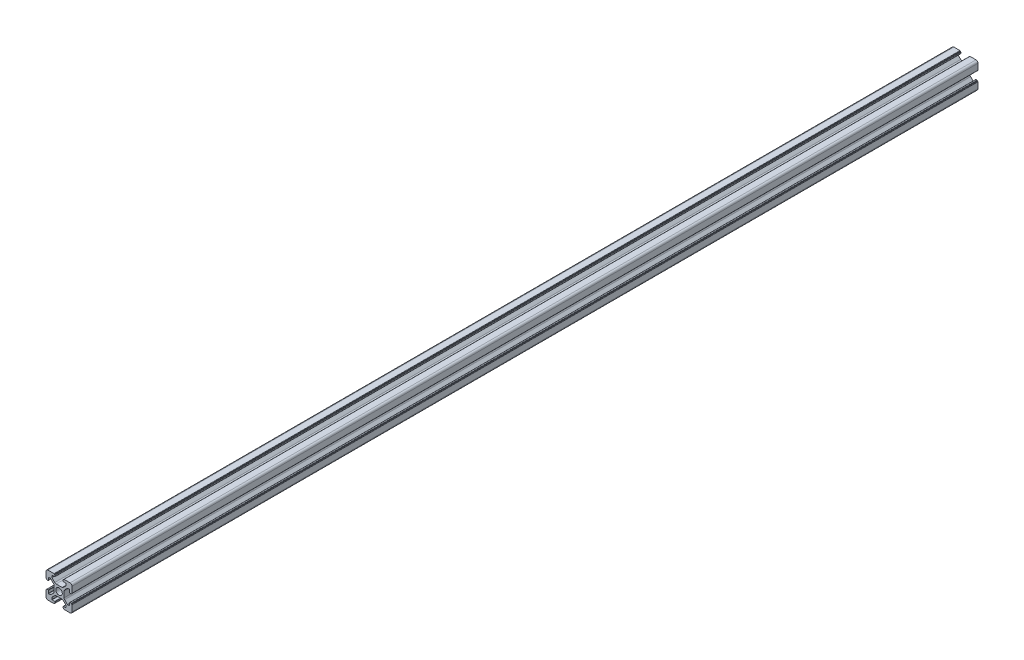
from build123d import *

# Parameters (mm, degrees)
SKETCH_1_R         = 2.5
EXTRUDE_1_DEPTH    = 1220
SKETCH1_R          = 16.771487081
CUT_EXTRUDE1_DEPTH = 525


with BuildPart() as part:
    # 草图1 → 凸台-拉伸1 (new body)
    with BuildSketch(Plane.XY):
        with BuildLine():
            Line((-8.502261885, -10.002261885), (-3.85, -10.002261885))
            ThreePointArc((-3.85, -10.002261885), (-3.673223305, -9.929038581), (-3.6, -9.752261885))
            Line((-3.6, -9.752261885), (-3.6, -9.502261885))
            Line((-3.6, -9.502261885), (-3.35, -9.502261885))
            ThreePointArc((-3.35, -9.502261885), (-3.173223305, -9.429038581), (-3.1, -9.252261885))
            Line((-3.1, -9.252261885), (-3.1, -8.45))
            ThreePointArc((-3.1, -8.45), (-3.173223305, -8.273223305), (-3.35, -8.2))
            Line((-3.35, -8.2), (-5.25, -8.2))
            ThreePointArc((-5.25, -8.2), (-5.426776695, -8.126776695), (-5.5, -7.95))
            Line((-5.5, -7.95), (-5.5, -6.664213562))
            ThreePointArc((-5.5, -6.664213562), (-5.480969883, -6.568542704), (-5.426776695, -6.487436867))
            Line((-5.426776695, -6.487436867), (-3.278679656, -4.339339828))
            ThreePointArc((-3.278679656, -4.339339828), (-2.792044633, -4.014180701), (-2.218019485, -3.9))
            Line((-2.218019485, -3.9), (2.218019485, -3.9))
            ThreePointArc((2.218019485, -3.9), (2.792044633, -4.014180701), (3.278679656, -4.339339828))
            Line((3.278679656, -4.339339828), (5.426776695, -6.487436867))
            ThreePointArc((5.426776695, -6.487436867), (5.480969883, -6.568542704), (5.5, -6.664213562))
            Line((5.5, -6.664213562), (5.5, -7.95))
            ThreePointArc((5.5, -7.95), (5.426776695, -8.126776695), (5.25, -8.2))
            Line((5.25, -8.2), (3.35, -8.2))
            ThreePointArc((3.35, -8.2), (3.173223305, -8.273223305), (3.1, -8.45))
            Line((3.1, -8.45), (3.1, -9.252261885))
            ThreePointArc((3.1, -9.252261885), (3.173223305, -9.429038581), (3.35, -9.502261885))
            Line((3.35, -9.502261885), (3.6, -9.502261885))
            Line((3.6, -9.502261885), (3.6, -9.752261885))
            ThreePointArc((3.6, -9.752261885), (3.673223305, -9.929038581), (3.85, -10.002261885))
            Line((3.85, -10.002261885), (8.502261885, -10.002261885))
            ThreePointArc((8.502261885, -10.002261885), (9.562922057, -9.562922057), (10.002261885, -8.502261885))
            Line((10.002261885, -8.502261885), (10.002261885, -3.85))
            ThreePointArc((10.002261885, -3.85), (9.929038581, -3.673223305), (9.752261885, -3.6))
            Line((9.752261885, -3.6), (9.502261885, -3.6))
            Line((9.502261885, -3.6), (9.502261885, -3.35))
            ThreePointArc((9.502261885, -3.35), (9.429038581, -3.173223305), (9.252261885, -3.1))
            Line((9.252261885, -3.1), (8.45, -3.1))
            ThreePointArc((8.45, -3.1), (8.273223305, -3.173223305), (8.2, -3.35))
            Line((8.2, -3.35), (8.2, -5.25))
            ThreePointArc((8.2, -5.25), (8.126776695, -5.426776695), (7.95, -5.5))
            Line((7.95, -5.5), (6.664213562, -5.5))
            ThreePointArc((6.664213562, -5.5), (6.568542704, -5.480969883), (6.487436867, -5.426776695))
            Line((6.487436867, -5.426776695), (4.339339828, -3.278679656))
            ThreePointArc((4.339339828, -3.278679656), (4.014180701, -2.792044633), (3.9, -2.218019485))
            Line((3.9, -2.218019485), (3.9, 2.218019485))
            ThreePointArc((3.9, 2.218019485), (4.014180701, 2.792044633), (4.339339828, 3.278679656))
            Line((4.339339828, 3.278679656), (6.487436867, 5.426776695))
            ThreePointArc((6.487436867, 5.426776695), (6.568542704, 5.480969883), (6.664213562, 5.5))
            Line((6.664213562, 5.5), (7.95, 5.5))
            ThreePointArc((7.95, 5.5), (8.126776695, 5.426776695), (8.2, 5.25))
            Line((8.2, 5.25), (8.2, 3.35))
            ThreePointArc((8.2, 3.35), (8.273223305, 3.173223305), (8.45, 3.1))
            Line((8.45, 3.1), (9.252261885, 3.1))
            ThreePointArc((9.252261885, 3.1), (9.429038581, 3.173223305), (9.502261885, 3.35))
            Line((9.502261885, 3.35), (9.502261885, 3.6))
            Line((9.502261885, 3.6), (9.752261885, 3.6))
            ThreePointArc((9.752261885, 3.6), (9.929038581, 3.673223305), (10.002261885, 3.85))
            Line((10.002261885, 3.85), (10.002261885, 8.502261885))
            ThreePointArc((10.002261885, 8.502261885), (9.562922057, 9.562922057), (8.502261885, 10.002261885))
            Line((8.502261885, 10.002261885), (3.85, 10.002261885))
            ThreePointArc((3.85, 10.002261885), (3.673223305, 9.929038581), (3.6, 9.752261885))
            Line((3.6, 9.752261885), (3.6, 9.502261885))
            Line((3.6, 9.502261885), (3.35, 9.502261885))
            ThreePointArc((3.35, 9.502261885), (3.173223305, 9.429038581), (3.1, 9.252261885))
            Line((3.1, 9.252261885), (3.1, 8.45))
            ThreePointArc((3.1, 8.45), (3.173223305, 8.273223305), (3.35, 8.2))
            Line((3.35, 8.2), (5.25, 8.2))
            ThreePointArc((5.25, 8.2), (5.426776695, 8.126776695), (5.5, 7.95))
            Line((5.5, 7.95), (5.5, 6.664213562))
            ThreePointArc((5.5, 6.664213562), (5.480969883, 6.568542704), (5.426776695, 6.487436867))
            Line((5.426776695, 6.487436867), (3.278679656, 4.339339828))
            ThreePointArc((3.278679656, 4.339339828), (2.792044633, 4.014180701), (2.218019485, 3.9))
            Line((2.218019485, 3.9), (-2.218019485, 3.9))
            ThreePointArc((-2.218019485, 3.9), (-2.792044633, 4.014180701), (-3.278679656, 4.339339828))
            Line((-3.278679656, 4.339339828), (-5.426776695, 6.487436867))
            ThreePointArc((-5.426776695, 6.487436867), (-5.480969883, 6.568542704), (-5.5, 6.664213562))
            Line((-5.5, 6.664213562), (-5.5, 7.95))
            ThreePointArc((-5.5, 7.95), (-5.426776695, 8.126776695), (-5.25, 8.2))
            Line((-5.25, 8.2), (-3.35, 8.2))
            ThreePointArc((-3.35, 8.2), (-3.173223305, 8.273223305), (-3.1, 8.45))
            Line((-3.1, 8.45), (-3.1, 9.252261885))
            ThreePointArc((-3.1, 9.252261885), (-3.173223305, 9.429038581), (-3.35, 9.502261885))
            Line((-3.35, 9.502261885), (-3.6, 9.502261885))
            Line((-3.6, 9.502261885), (-3.6, 9.752261885))
            ThreePointArc((-3.6, 9.752261885), (-3.673223305, 9.929038581), (-3.85, 10.002261885))
            Line((-3.85, 10.002261885), (-8.502261885, 10.002261885))
            ThreePointArc((-8.502261885, 10.002261885), (-9.562922057, 9.562922057), (-10.002261885, 8.502261885))
            Line((-10.002261885, 8.502261885), (-10.002261885, 3.85))
            ThreePointArc((-10.002261885, 3.85), (-9.929038581, 3.673223305), (-9.752261885, 3.6))
            Line((-9.752261885, 3.6), (-9.502261885, 3.6))
            Line((-9.502261885, 3.6), (-9.502261885, 3.35))
            ThreePointArc((-9.502261885, 3.35), (-9.429038581, 3.173223305), (-9.252261885, 3.1))
            Line((-9.252261885, 3.1), (-8.45, 3.1))
            ThreePointArc((-8.45, 3.1), (-8.273223305, 3.173223305), (-8.2, 3.35))
            Line((-8.2, 3.35), (-8.2, 5.25))
            ThreePointArc((-8.2, 5.25), (-8.126776695, 5.426776695), (-7.95, 5.5))
            Line((-7.95, 5.5), (-6.664213562, 5.5))
            ThreePointArc((-6.664213562, 5.5), (-6.568542704, 5.480969883), (-6.487436867, 5.426776695))
            Line((-6.487436867, 5.426776695), (-4.339339828, 3.278679656))
            ThreePointArc((-4.339339828, 3.278679656), (-4.014180701, 2.792044633), (-3.9, 2.218019485))
            Line((-3.9, 2.218019485), (-3.9, -2.218019485))
            ThreePointArc((-3.9, -2.218019485), (-4.014180701, -2.792044633), (-4.339339828, -3.278679656))
            Line((-4.339339828, -3.278679656), (-6.487436867, -5.426776695))
            ThreePointArc((-6.487436867, -5.426776695), (-6.568542704, -5.480969883), (-6.664213562, -5.5))
            Line((-6.664213562, -5.5), (-7.95, -5.5))
            ThreePointArc((-7.95, -5.5), (-8.126776695, -5.426776695), (-8.2, -5.25))
            Line((-8.2, -5.25), (-8.2, -3.35))
            ThreePointArc((-8.2, -3.35), (-8.273223305, -3.173223305), (-8.45, -3.1))
            Line((-8.45, -3.1), (-9.252261885, -3.1))
            ThreePointArc((-9.252261885, -3.1), (-9.429038581, -3.173223305), (-9.502261885, -3.35))
            Line((-9.502261885, -3.35), (-9.502261885, -3.6))
            Line((-9.502261885, -3.6), (-9.752261885, -3.6))
            ThreePointArc((-9.752261885, -3.6), (-9.929038581, -3.673223305), (-10.002261885, -3.85))
            Line((-10.002261885, -3.85), (-10.002261885, -8.502261885))
            ThreePointArc((-10.002261885, -8.502261885), (-9.562922057, -9.562922057), (-8.502261885, -10.002261885))
        make_face()
        Circle(SKETCH_1_R, mode=Mode.SUBTRACT)
    extrude(amount=EXTRUDE_1_DEPTH)

    # Sketch1 → Cut-Extrude1 (cut, through all)
    with BuildSketch(Plane.XY.offset(524)):
        Circle(SKETCH1_R)
    extrude(amount=-CUT_EXTRUDE1_DEPTH, mode=Mode.SUBTRACT)


solid = part.part
